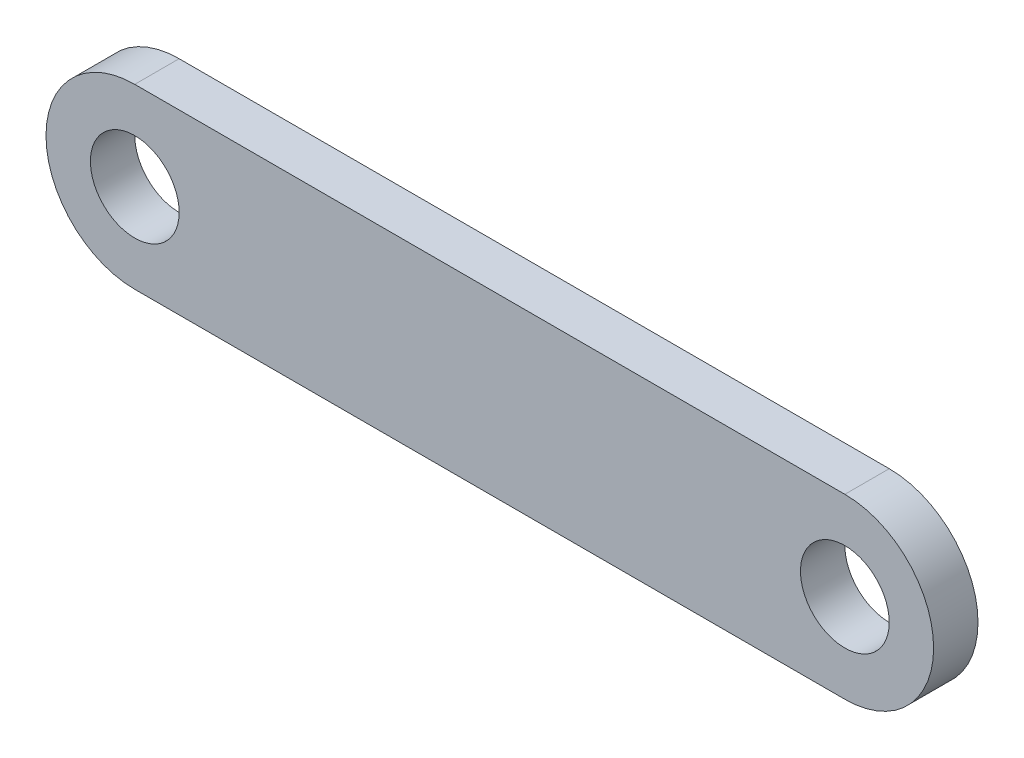
from build123d import *

# Parameters (mm, degrees)
SKETCH1_R           = 3.175
BOSS_EXTRUDE2_DEPTH = 3.175


with BuildPart() as part:
    # Sketch1 → Boss-Extrude2 (new body)
    with BuildSketch(Plane.XY):
        with BuildLine():
            Line((-25.4, 6.35), (25.4, 6.35))
            ThreePointArc((25.4, 6.35), (31.75, 0), (25.4, -6.35))
            Line((25.4, -6.35), (-25.4, -6.35))
            ThreePointArc((-25.4, -6.35), (-31.75, 0), (-25.4, 6.35))
        make_face()
        with Locations((-25.4, 0)):
            Circle(SKETCH1_R, mode=Mode.SUBTRACT)
        with Locations((25.4, 0)):
            Circle(SKETCH1_R, mode=Mode.SUBTRACT)
    extrude(amount=BOSS_EXTRUDE2_DEPTH)


solid = part.part
